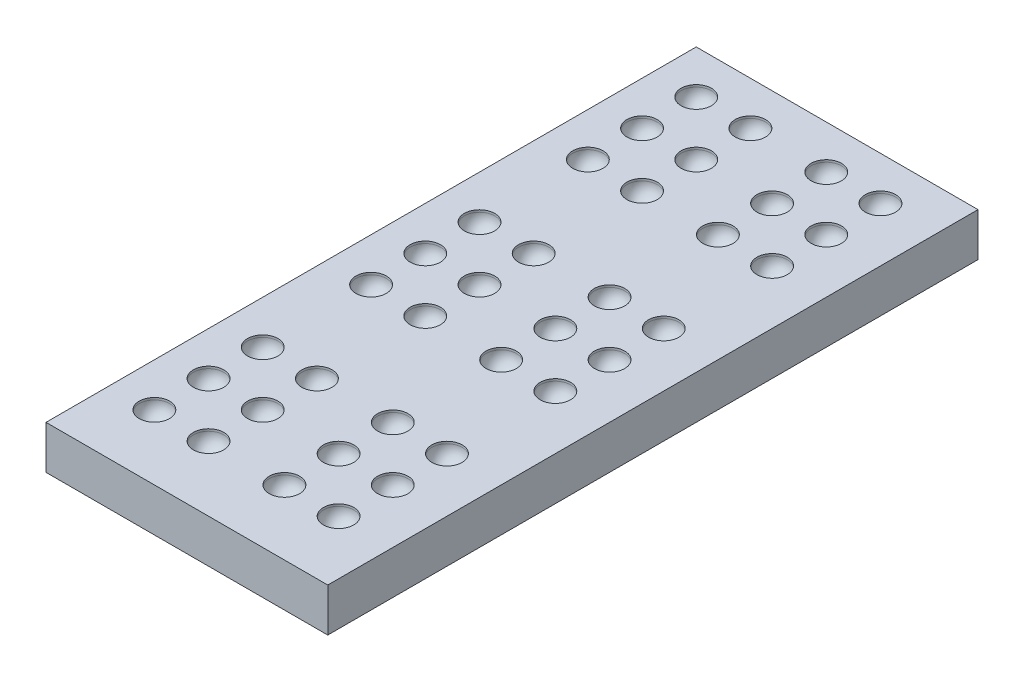
from build123d import *

# Parameters (mm, degrees)
SKETCH1_W            = 13
SKETCH1_H            = 30
BOSS_EXTRUDE1_DEPTH  = 2
SKETCH2_R            = 0.7
CUT_EXTRUDE1_DEPTH   = 0.1
LPATTERN1_COUNT      = 2
LPATTERN1_PITCH      = 2.5
LPATTERN1_COUNT_DIR2 = 3
LPATTERN1_PITCH_DIR2 = 2.5
LPATTERN3_COUNT      = 2
LPATTERN3_PITCH      = 6
LPATTERN3_COUNT_DIR2 = 3
LPATTERN3_PITCH_DIR2 = 10


with BuildPart() as part:
    # Sketch1 → Boss-Extrude1 (new body)
    with BuildSketch(Plane(origin=(0, 0, 0), x_dir=(1, 0, 0), z_dir=(0, 1, 0))):
        with Locations((6.5, 15)):
            Rectangle(SKETCH1_W, SKETCH1_H)
    extrude(amount=BOSS_EXTRUDE1_DEPTH)

    # Sketch2 → Cut-Extrude1 (cut)
    with BuildSketch(Plane(origin=(0, 2, 0), x_dir=(1, 0, 0), z_dir=(0, 1, 0))):
        with Locations((2, 28)):
            Circle(SKETCH2_R)
        with Locations((4.5, 28)):
            Circle(SKETCH2_R)
        with Locations((4.5, 25.5)):
            Circle(SKETCH2_R)
        with Locations((4.5, 23)):
            Circle(SKETCH2_R)
        with Locations((2, 25.5)):
            Circle(SKETCH2_R)
        with Locations((2, 23)):
            Circle(SKETCH2_R)
    cut_extrude1 = extrude(amount=-CUT_EXTRUDE1_DEPTH, mode=Mode.SUBTRACT)

    # Sketch3 → Cut-Revolve1 (revolve, cut)
    with BuildSketch(Plane(origin=(0, 1.9, 0), x_dir=(1, 0, 0), z_dir=(0, 1, 0))):
        with BuildLine():
            Line((2, 28.7), (2, 27.3))
            ThreePointArc((2, 27.3), (1.3, 28), (2, 28.7))
        make_face()
    cut_revolve1 = revolve(axis=Axis((2, 1.9, -28.7), (0, 0, 1)), mode=Mode.SUBTRACT)

    # LPattern1: Cut-Revolve1 2 × 3
    with Locations(*[(i * LPATTERN1_PITCH, 0, j * LPATTERN1_PITCH_DIR2) for i in range(LPATTERN1_COUNT) for j in range(LPATTERN1_COUNT_DIR2) if (i, j) != (0, 0)]):
        add(cut_revolve1, mode=Mode.SUBTRACT)

    # LPattern3: Cut-Extrude1, Cut-Revolve1 2 × 3
    with Locations(*[(i * LPATTERN3_PITCH, 0, j * LPATTERN3_PITCH_DIR2) for i in range(LPATTERN3_COUNT) for j in range(LPATTERN3_COUNT_DIR2) if (i, j) != (0, 0)]):
        add(cut_extrude1, mode=Mode.SUBTRACT)
        add(cut_revolve1, mode=Mode.SUBTRACT)

    # LPattern3 copy 1 sketch → LPattern3 copy 1 (revolve, cut)
    with BuildSketch(Plane(origin=(0, 1.9, 12.5), x_dir=(1, 0, 0), z_dir=(0, 1, 0))):
        with BuildLine():
            Line((2, 28.7), (2, 27.3))
            ThreePointArc((2, 27.3), (1.3, 28), (2, 28.7))
        make_face()
    revolve(axis=Axis((2, 1.9, -16.2), (0, 0, 1)), mode=Mode.SUBTRACT)

    # LPattern3 copy 2 sketch → LPattern3 copy 2 (revolve, cut)
    with BuildSketch(Plane(origin=(0, 1.9, 22.5), x_dir=(1, 0, 0), z_dir=(0, 1, 0))):
        with BuildLine():
            Line((2, 28.7), (2, 27.3))
            ThreePointArc((2, 27.3), (1.3, 28), (2, 28.7))
        make_face()
    revolve(axis=Axis((2, 1.9, -6.2), (0, 0, 1)), mode=Mode.SUBTRACT)

    # LPattern3 copy 3 sketch → LPattern3 copy 3 (revolve, cut)
    with BuildSketch(Plane(origin=(6, 1.9, 2.5), x_dir=(1, 0, 0), z_dir=(0, 1, 0))):
        with BuildLine():
            Line((2, 28.7), (2, 27.3))
            ThreePointArc((2, 27.3), (1.3, 28), (2, 28.7))
        make_face()
    revolve(axis=Axis((8, 1.9, -26.2), (0, 0, 1)), mode=Mode.SUBTRACT)

    # LPattern3 copy 4 sketch → LPattern3 copy 4 (revolve, cut)
    with BuildSketch(Plane(origin=(6, 1.9, 12.5), x_dir=(1, 0, 0), z_dir=(0, 1, 0))):
        with BuildLine():
            Line((2, 28.7), (2, 27.3))
            ThreePointArc((2, 27.3), (1.3, 28), (2, 28.7))
        make_face()
    revolve(axis=Axis((8, 1.9, -16.2), (0, 0, 1)), mode=Mode.SUBTRACT)

    # LPattern3 copy 5 sketch → LPattern3 copy 5 (revolve, cut)
    with BuildSketch(Plane(origin=(6, 1.9, 22.5), x_dir=(1, 0, 0), z_dir=(0, 1, 0))):
        with BuildLine():
            Line((2, 28.7), (2, 27.3))
            ThreePointArc((2, 27.3), (1.3, 28), (2, 28.7))
        make_face()
    revolve(axis=Axis((8, 1.9, -6.2), (0, 0, 1)), mode=Mode.SUBTRACT)

    # LPattern3 copy 6 sketch → LPattern3 copy 6 (revolve, cut)
    with BuildSketch(Plane(origin=(0, 1.9, 15), x_dir=(1, 0, 0), z_dir=(0, 1, 0))):
        with BuildLine():
            Line((2, 28.7), (2, 27.3))
            ThreePointArc((2, 27.3), (1.3, 28), (2, 28.7))
        make_face()
    revolve(axis=Axis((2, 1.9, -13.7), (0, 0, 1)), mode=Mode.SUBTRACT)

    # LPattern3 copy 7 sketch → LPattern3 copy 7 (revolve, cut)
    with BuildSketch(Plane(origin=(0, 1.9, 25), x_dir=(1, 0, 0), z_dir=(0, 1, 0))):
        with BuildLine():
            Line((2, 28.7), (2, 27.3))
            ThreePointArc((2, 27.3), (1.3, 28), (2, 28.7))
        make_face()
    revolve(axis=Axis((2, 1.9, -3.7), (0, 0, 1)), mode=Mode.SUBTRACT)

    # LPattern3 copy 8 sketch → LPattern3 copy 8 (revolve, cut)
    with BuildSketch(Plane(origin=(6, 1.9, 5), x_dir=(1, 0, 0), z_dir=(0, 1, 0))):
        with BuildLine():
            Line((2, 28.7), (2, 27.3))
            ThreePointArc((2, 27.3), (1.3, 28), (2, 28.7))
        make_face()
    revolve(axis=Axis((8, 1.9, -23.7), (0, 0, 1)), mode=Mode.SUBTRACT)

    # LPattern3 copy 9 sketch → LPattern3 copy 9 (revolve, cut)
    with BuildSketch(Plane(origin=(6, 1.9, 15), x_dir=(1, 0, 0), z_dir=(0, 1, 0))):
        with BuildLine():
            Line((2, 28.7), (2, 27.3))
            ThreePointArc((2, 27.3), (1.3, 28), (2, 28.7))
        make_face()
    revolve(axis=Axis((8, 1.9, -13.7), (0, 0, 1)), mode=Mode.SUBTRACT)

    # LPattern3 copy 10 sketch → LPattern3 copy 10 (revolve, cut)
    with BuildSketch(Plane(origin=(6, 1.9, 25), x_dir=(1, 0, 0), z_dir=(0, 1, 0))):
        with BuildLine():
            Line((2, 28.7), (2, 27.3))
            ThreePointArc((2, 27.3), (1.3, 28), (2, 28.7))
        make_face()
    revolve(axis=Axis((8, 1.9, -3.7), (0, 0, 1)), mode=Mode.SUBTRACT)

    # LPattern3 copy 11 sketch → LPattern3 copy 11 (revolve, cut)
    with BuildSketch(Plane(origin=(2.5, 1.9, 10), x_dir=(1, 0, 0), z_dir=(0, 1, 0))):
        with BuildLine():
            Line((2, 28.7), (2, 27.3))
            ThreePointArc((2, 27.3), (1.3, 28), (2, 28.7))
        make_face()
    revolve(axis=Axis((4.5, 1.9, -18.7), (0, 0, 1)), mode=Mode.SUBTRACT)

    # LPattern3 copy 12 sketch → LPattern3 copy 12 (revolve, cut)
    with BuildSketch(Plane(origin=(2.5, 1.9, 20), x_dir=(1, 0, 0), z_dir=(0, 1, 0))):
        with BuildLine():
            Line((2, 28.7), (2, 27.3))
            ThreePointArc((2, 27.3), (1.3, 28), (2, 28.7))
        make_face()
    revolve(axis=Axis((4.5, 1.9, -8.7), (0, 0, 1)), mode=Mode.SUBTRACT)

    # LPattern3 copy 13 sketch → LPattern3 copy 13 (revolve, cut)
    with BuildSketch(Plane(origin=(8.5, 1.9, 0), x_dir=(1, 0, 0), z_dir=(0, 1, 0))):
        with BuildLine():
            Line((2, 28.7), (2, 27.3))
            ThreePointArc((2, 27.3), (1.3, 28), (2, 28.7))
        make_face()
    revolve(axis=Axis((10.5, 1.9, -28.7), (0, 0, 1)), mode=Mode.SUBTRACT)

    # LPattern3 copy 14 sketch → LPattern3 copy 14 (revolve, cut)
    with BuildSketch(Plane(origin=(8.5, 1.9, 10), x_dir=(1, 0, 0), z_dir=(0, 1, 0))):
        with BuildLine():
            Line((2, 28.7), (2, 27.3))
            ThreePointArc((2, 27.3), (1.3, 28), (2, 28.7))
        make_face()
    revolve(axis=Axis((10.5, 1.9, -18.7), (0, 0, 1)), mode=Mode.SUBTRACT)

    # LPattern3 copy 15 sketch → LPattern3 copy 15 (revolve, cut)
    with BuildSketch(Plane(origin=(8.5, 1.9, 20), x_dir=(1, 0, 0), z_dir=(0, 1, 0))):
        with BuildLine():
            Line((2, 28.7), (2, 27.3))
            ThreePointArc((2, 27.3), (1.3, 28), (2, 28.7))
        make_face()
    revolve(axis=Axis((10.5, 1.9, -8.7), (0, 0, 1)), mode=Mode.SUBTRACT)

    # LPattern3 copy 16 sketch → LPattern3 copy 16 (revolve, cut)
    with BuildSketch(Plane(origin=(2.5, 1.9, 12.5), x_dir=(1, 0, 0), z_dir=(0, 1, 0))):
        with BuildLine():
            Line((2, 28.7), (2, 27.3))
            ThreePointArc((2, 27.3), (1.3, 28), (2, 28.7))
        make_face()
    revolve(axis=Axis((4.5, 1.9, -16.2), (0, 0, 1)), mode=Mode.SUBTRACT)

    # LPattern3 copy 17 sketch → LPattern3 copy 17 (revolve, cut)
    with BuildSketch(Plane(origin=(2.5, 1.9, 22.5), x_dir=(1, 0, 0), z_dir=(0, 1, 0))):
        with BuildLine():
            Line((2, 28.7), (2, 27.3))
            ThreePointArc((2, 27.3), (1.3, 28), (2, 28.7))
        make_face()
    revolve(axis=Axis((4.5, 1.9, -6.2), (0, 0, 1)), mode=Mode.SUBTRACT)

    # LPattern3 copy 18 sketch → LPattern3 copy 18 (revolve, cut)
    with BuildSketch(Plane(origin=(8.5, 1.9, 2.5), x_dir=(1, 0, 0), z_dir=(0, 1, 0))):
        with BuildLine():
            Line((2, 28.7), (2, 27.3))
            ThreePointArc((2, 27.3), (1.3, 28), (2, 28.7))
        make_face()
    revolve(axis=Axis((10.5, 1.9, -26.2), (0, 0, 1)), mode=Mode.SUBTRACT)

    # LPattern3 copy 19 sketch → LPattern3 copy 19 (revolve, cut)
    with BuildSketch(Plane(origin=(8.5, 1.9, 12.5), x_dir=(1, 0, 0), z_dir=(0, 1, 0))):
        with BuildLine():
            Line((2, 28.7), (2, 27.3))
            ThreePointArc((2, 27.3), (1.3, 28), (2, 28.7))
        make_face()
    revolve(axis=Axis((10.5, 1.9, -16.2), (0, 0, 1)), mode=Mode.SUBTRACT)

    # LPattern3 copy 20 sketch → LPattern3 copy 20 (revolve, cut)
    with BuildSketch(Plane(origin=(8.5, 1.9, 22.5), x_dir=(1, 0, 0), z_dir=(0, 1, 0))):
        with BuildLine():
            Line((2, 28.7), (2, 27.3))
            ThreePointArc((2, 27.3), (1.3, 28), (2, 28.7))
        make_face()
    revolve(axis=Axis((10.5, 1.9, -6.2), (0, 0, 1)), mode=Mode.SUBTRACT)

    # LPattern3 copy 21 sketch → LPattern3 copy 21 (revolve, cut)
    with BuildSketch(Plane(origin=(2.5, 1.9, 15), x_dir=(1, 0, 0), z_dir=(0, 1, 0))):
        with BuildLine():
            Line((2, 28.7), (2, 27.3))
            ThreePointArc((2, 27.3), (1.3, 28), (2, 28.7))
        make_face()
    revolve(axis=Axis((4.5, 1.9, -13.7), (0, 0, 1)), mode=Mode.SUBTRACT)

    # LPattern3 copy 22 sketch → LPattern3 copy 22 (revolve, cut)
    with BuildSketch(Plane(origin=(2.5, 1.9, 25), x_dir=(1, 0, 0), z_dir=(0, 1, 0))):
        with BuildLine():
            Line((2, 28.7), (2, 27.3))
            ThreePointArc((2, 27.3), (1.3, 28), (2, 28.7))
        make_face()
    revolve(axis=Axis((4.5, 1.9, -3.7), (0, 0, 1)), mode=Mode.SUBTRACT)

    # LPattern3 copy 23 sketch → LPattern3 copy 23 (revolve, cut)
    with BuildSketch(Plane(origin=(8.5, 1.9, 5), x_dir=(1, 0, 0), z_dir=(0, 1, 0))):
        with BuildLine():
            Line((2, 28.7), (2, 27.3))
            ThreePointArc((2, 27.3), (1.3, 28), (2, 28.7))
        make_face()
    revolve(axis=Axis((10.5, 1.9, -23.7), (0, 0, 1)), mode=Mode.SUBTRACT)

    # LPattern3 copy 24 sketch → LPattern3 copy 24 (revolve, cut)
    with BuildSketch(Plane(origin=(8.5, 1.9, 15), x_dir=(1, 0, 0), z_dir=(0, 1, 0))):
        with BuildLine():
            Line((2, 28.7), (2, 27.3))
            ThreePointArc((2, 27.3), (1.3, 28), (2, 28.7))
        make_face()
    revolve(axis=Axis((10.5, 1.9, -13.7), (0, 0, 1)), mode=Mode.SUBTRACT)

    # LPattern3 copy 25 sketch → LPattern3 copy 25 (revolve, cut)
    with BuildSketch(Plane(origin=(8.5, 1.9, 25), x_dir=(1, 0, 0), z_dir=(0, 1, 0))):
        with BuildLine():
            Line((2, 28.7), (2, 27.3))
            ThreePointArc((2, 27.3), (1.3, 28), (2, 28.7))
        make_face()
    revolve(axis=Axis((10.5, 1.9, -3.7), (0, 0, 1)), mode=Mode.SUBTRACT)


solid = part.part
